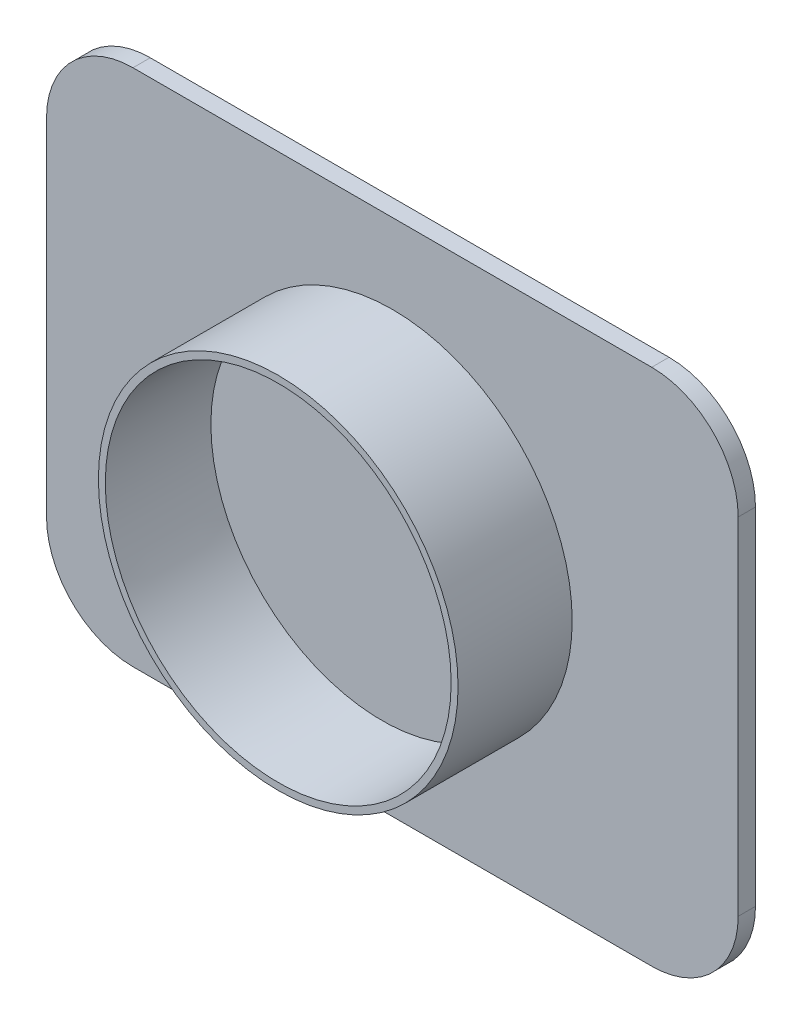
from build123d import *

# Parameters (mm, degrees)
ESQUISSE1_R             = 10.4
BOSS_EXTRU_1_DEPTH      = 6.6
ESQUISSE2_R             = 10
ENL_V_MAT_EXTRU_1_DEPTH = 6
ENL_V_MAT_EXTRU_1_TAPER = 1
ESQUISSE3_W             = 40
ESQUISSE3_H             = 30
BOSS_EXTRU_2_DEPTH      = 1
CONG_1_R                = 5


with BuildPart() as part:
    # Esquisse1 → Boss.-Extru.1 (new body)
    with BuildSketch(Plane.XY):
        Circle(ESQUISSE1_R)
    extrude(amount=BOSS_EXTRU_1_DEPTH)

    # Esquisse2 → Enlèv. mat.-Extru.1 (cut)
    with BuildSketch(Plane.XY.offset(6.6)):
        Circle(ESQUISSE2_R)
    extrude(amount=-ENL_V_MAT_EXTRU_1_DEPTH, taper=ENL_V_MAT_EXTRU_1_TAPER, mode=Mode.SUBTRACT)

    # Esquisse3 → Boss.-Extru.2 (add)
    with BuildSketch(Plane.XY):
        Rectangle(ESQUISSE3_W, ESQUISSE3_H)
    extrude(amount=-BOSS_EXTRU_2_DEPTH)

    # Congé1
    cong_1_edges = [part.edges().sort_by_distance(p)[0] for p in [
        (-20, -15, -0.5),
        (-20, 15, -0.5),
        (20, 15, -0.5),
        (20, -15, -0.5),
    ]]
    fillet(cong_1_edges, radius=CONG_1_R)


solid = part.part
